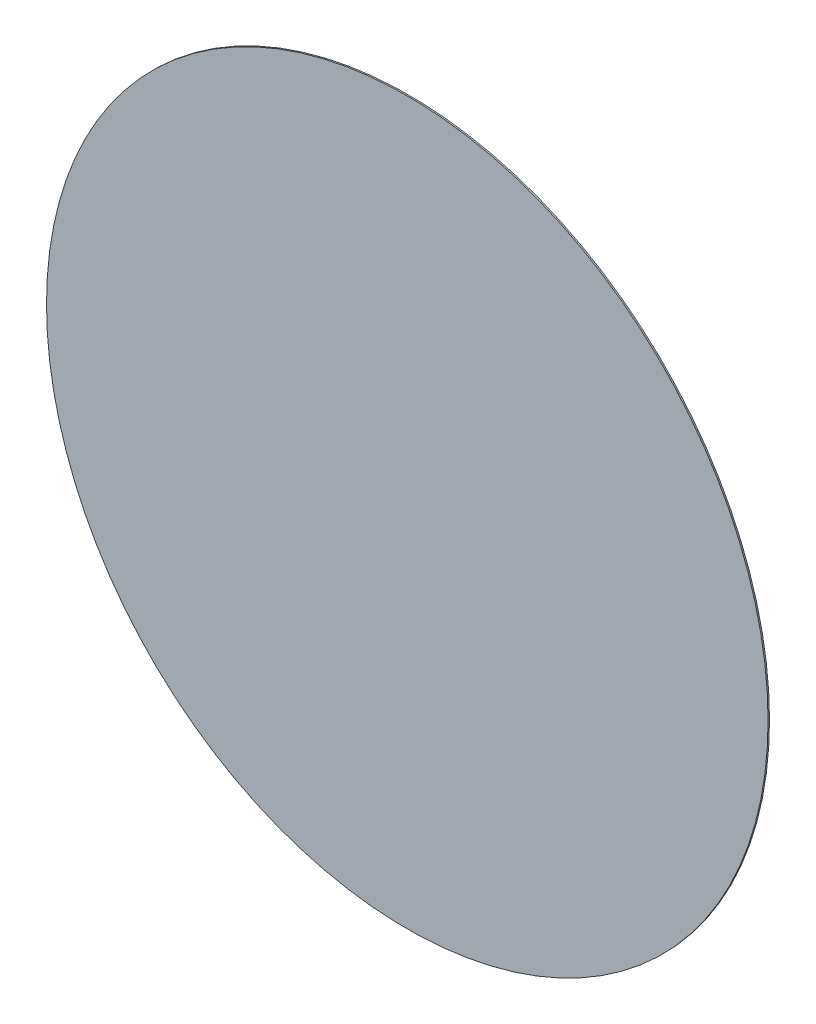
from build123d import *

# Parameters (mm, degrees)
SKETCH1_R           = 127
BOSS_EXTRUDE1_DEPTH = 0.5


with BuildPart() as part:
    # Sketch1 → Boss-Extrude1 (new body)
    with BuildSketch(Plane.XY):
        Circle(SKETCH1_R)
    extrude(amount=BOSS_EXTRUDE1_DEPTH)


solid = part.part
